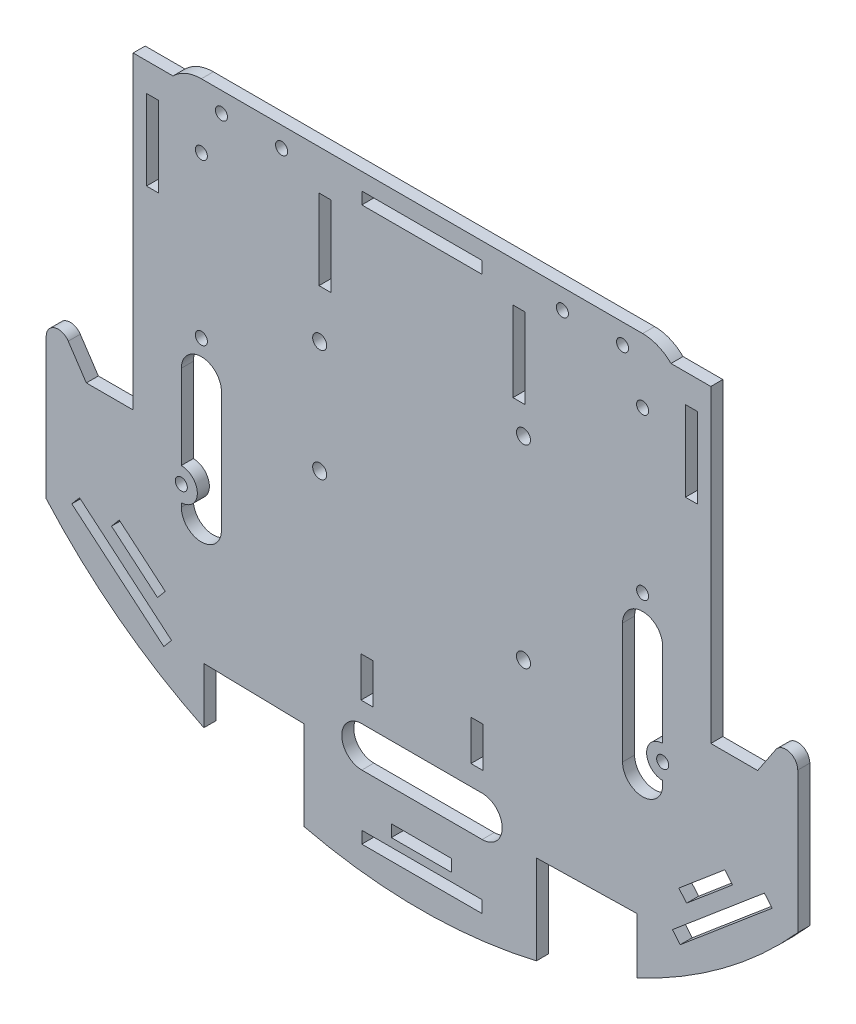
from build123d import *

# Parameters (mm, degrees)
SKETCH1_R           = 1.5
BOSS_EXTRUDE1_DEPTH = 3
SKETCH12_W          = 3
SKETCH12_H          = 20
BOSS_EXTRUDE3_DEPTH = 3
SKETCH13_W          = 3
SKETCH13_H          = 20
CUT_EXTRUDE5_DEPTH  = 3
SKETCH15_W          = 30
SKETCH15_H          = 3
BOSS_EXTRUDE4_DEPTH = 3
CUT_EXTRUDE7_DEPTH  = 3
CUT_EXTRUDE8_DEPTH  = 5
SKETCH18_R          = 1.5
SKETCH18_W          = 30
SKETCH18_H          = 3
CUT_EXTRUDE9_DEPTH  = 3
FILLET4_R           = 3
SKETCH25_R          = 1.5
CUT_EXTRUDE11_DEPTH = 10
CUT_EXTRUDE12_DEPTH = 10
SKETCH27_W          = 15
SKETCH27_H          = 3
CUT_EXTRUDE13_DEPTH = 10
SKETCH34_W          = 3
SKETCH34_H          = 10
CUT_EXTRUDE14_DEPTH = 10
SKETCH35_R          = 1.75
CUT_EXTRUDE15_DEPTH = 10


with BuildPart() as part:
    # Sketch1 → Boss-Extrude1 (new body)
    with BuildSketch(Plane.XY):
        with BuildLine():
            Line((-65, 40), (-65, -45))
            ThreePointArc((-65, -45), (-62.071067812, -52.071067812), (-55, -55))
            Line((-55, -55), (55, -55))
            ThreePointArc((55, -55), (62.071067812, -52.071067812), (65, -45))
            Line((65, -45), (65, 40))
            ThreePointArc((65, 40), (62.071067812, 47.071067812), (55, 50))
            Line((55, 50), (-55, 50))
            ThreePointArc((-55, 50), (-62.071067812, 47.071067812), (-65, 40))
        make_face()
        with Locations((-50, 45)):
            Circle(SKETCH1_R, mode=Mode.SUBTRACT)
        with Locations((50, 45)):
            Circle(SKETCH1_R, mode=Mode.SUBTRACT)
        with Locations((-60, -40)):
            Circle(SKETCH1_R, mode=Mode.SUBTRACT)
        with Locations((60, -40)):
            Circle(SKETCH1_R, mode=Mode.SUBTRACT)
    extrude(amount=BOSS_EXTRUDE1_DEPTH)

    # Sketch12 → Boss-Extrude3 (add)
    with BuildSketch(Plane(origin=(0, 0, 0), x_dir=(-1, 0, 0), z_dir=(0, 0, -1))):
        with BuildLine():
            Line((65, 40), (65, -30))
            Line((65, -30), (72, -30))
            Line((72, -30), (72, 40))
            Line((72, 40), (72, 47.071067812))
            Line((72, 47.071067812), (62.071067812, 47.071067812))
            ThreePointArc((62.071067812, 47.071067812), (64.238795325, 43.826834324), (65, 40))
        make_face()
        with Locations((67.174969976, 30)):
            Rectangle(SKETCH12_W, SKETCH12_H, mode=Mode.SUBTRACT)
        with BuildLine():
            Line((-72, 40), (-72, -30))
            Line((-72, -30), (-65, -30))
            Line((-65, -30), (-65, 40))
            ThreePointArc((-65, 40), (-64.238795325, 43.826834324), (-62.071067812, 47.071067812))
            Line((-62.071067812, 47.071067812), (-72, 47.071067812))
            Line((-72, 47.071067812), (-72, 40))
        make_face()
        with Locations((-67.174969976, 30)):
            Rectangle(SKETCH12_W, SKETCH12_H, mode=Mode.SUBTRACT)
    extrude(amount=-BOSS_EXTRUDE3_DEPTH)

    # Sketch13 → Cut-Extrude5 (cut)
    with BuildSketch(Plane(origin=(0, 0, 0), x_dir=(-1, 0, 0), z_dir=(0, 0, -1))):
        with Locations((24.174969976, 30)):
            Rectangle(SKETCH13_W, SKETCH13_H)
        with Locations((-24.174969976, 30)):
            Rectangle(SKETCH13_W, SKETCH13_H)
    extrude(amount=-CUT_EXTRUDE5_DEPTH, mode=Mode.SUBTRACT)

    # Sketch15 → Boss-Extrude4 (add)
    with BuildSketch(Plane(origin=(0, 0, 0), x_dir=(-1, 0, 0), z_dir=(0, 0, -1))):
        with BuildLine():
            Line((73.674969976, -30), (72, -30))
            Line((72, -30), (65, -30))
            Line((65, -30), (65, -45))
            ThreePointArc((65, -45), (62.071067812, -52.071067812), (55, -55))
            Line((55, -55), (-55, -55))
            ThreePointArc((-55, -55), (-62.071067812, -52.071067812), (-65, -45))
            Line((-65, -45), (-65, -30))
            Line((-65, -30), (-72, -30))
            Line((-72, -30), (-73.674969976, -30))
            Line((-73.674969976, -30), (-83.674969976, -30))
            Line((-83.674969976, -30), (-93.674969976, -15))
            Line((-93.674969976, -15), (-93.674969976, -60))
            ThreePointArc((-93.674969976, -60), (-75.11867005, -76.957696294), (-53.544667826, -89.859717787))
            Line((-53.544667826, -89.859717787), (-53.544667826, -77.921197712))
            Line((-53.544667826, -77.921197712), (-43.544667826, -77.921197712))
            Line((-43.544667826, -77.921197712), (-28.544667826, -78.447755309))
            Line((-28.544667826, -78.447755309), (-28.544667826, -98.657929362))
            ThreePointArc((-28.544667826, -98.657929362), (0.412515012, -102.058251887), (29.36969785, -98.657929362))
            Line((29.36969785, -98.657929362), (29.36969785, -78.447755309))
            Line((29.36969785, -78.447755309), (44.36969785, -77.921197712))
            Line((44.36969785, -77.921197712), (54.36969785, -77.921197712))
            Line((54.36969785, -77.921197712), (54.36969785, -89.791641118))
            ThreePointArc((54.36969785, -89.791641118), (75.506234101, -76.853587855), (93.674969976, -60))
            Line((93.674969976, -60), (93.674969976, -15))
            Line((93.674969976, -15), (83.674969976, -30))
            Line((83.674969976, -30), (73.674969976, -30))
        make_face()
        Polygon((-64.364341028, -77.265224848), (-87.294606331, -57.920899244), (-85.360173771, -55.627872713), (-62.429908467, -74.972198318), align=None, mode=Mode.SUBTRACT)
        with Locations((0, -93.735273214)):
            Rectangle(SKETCH15_W, SKETCH15_H, mode=Mode.SUBTRACT)
        Polygon((-65.960254421, -67.497898332), (-77.422828052, -57.822702946), (-75.487788974, -55.53018822), (-64.025215344, -65.205383606), align=None, mode=Mode.SUBTRACT)
        Polygon((85.360173771, -55.627872713), (87.294606331, -57.920899244), (64.364341028, -77.265224848), (62.429908467, -74.972198318), align=None, mode=Mode.SUBTRACT)
        Polygon((77.394030345, -57.788043022), (65.932380202, -67.464332393), (63.997122328, -65.172002365), (75.458772471, -55.495712994), align=None, mode=Mode.SUBTRACT)
    extrude(amount=-BOSS_EXTRUDE4_DEPTH)

    # Sketch16 → Cut-Extrude7 (cut)
    with BuildSketch(Plane(origin=(0, 0, 0), x_dir=(-1, 0, 0), z_dir=(0, 0, -1))):
        with BuildLine():
            Line((-60, -44), (-60, -45))
            ThreePointArc((-60, -45), (-55, -50), (-50, -45))
            Line((-50, -45), (-50, -15))
            ThreePointArc((-50, -15), (-55, -10), (-60, -15))
            Line((-60, -15), (-60, -36))
            ThreePointArc((-60, -36), (-56, -40), (-60, -44))
        make_face()
        with BuildLine():
            Line((60, -36), (60, -15))
            ThreePointArc((60, -15), (55, -10), (50, -15))
            Line((50, -15), (50, -45))
            ThreePointArc((50, -45), (55, -50), (60, -45))
            Line((60, -45), (60, -44))
            ThreePointArc((60, -44), (56, -40), (60, -36))
        make_face()
    extrude(amount=-CUT_EXTRUDE7_DEPTH, mode=Mode.SUBTRACT)

    # Sketch17 → Cut-Extrude8 (cut)
    with BuildSketch(Plane(origin=(0, 0, 0), x_dir=(-1, 0, 0), z_dir=(0, 0, -1))):
        with BuildLine():
            Line((-15, -69.235273214), (15, -69.235273214))
            ThreePointArc((15, -69.235273214), (20, -74.235273214), (15, -79.235273214))
            Line((15, -79.235273214), (-15, -79.235273214))
            ThreePointArc((-15, -79.235273214), (-20, -74.235273214), (-15, -69.235273214))
        make_face()
    extrude(amount=-CUT_EXTRUDE8_DEPTH, mode=Mode.SUBTRACT)

    # Sketch18 → Cut-Extrude9 (cut)
    with BuildSketch(Plane(origin=(0, 0, 0), x_dir=(-1, 0, 0), z_dir=(0, 0, -1))):
        with Locations((55, 34)):
            Circle(SKETCH18_R)
        with Locations((55, -6)):
            Circle(SKETCH18_R)
        with Locations((-55, 34)):
            Circle(SKETCH18_R)
        with Locations((-55, -6)):
            Circle(SKETCH18_R)
        with Locations((0, 44.264726786)):
            Rectangle(SKETCH18_W, SKETCH18_H)
    extrude(amount=-CUT_EXTRUDE9_DEPTH, mode=Mode.SUBTRACT)

    # Fillet4
    fillet4_edges = [part.edges().sort_by_distance(p)[0] for p in [
        (93.674969976, -15, 1.5),
        (-93.674969976, -15, 1.5),
    ]]
    fillet(fillet4_edges, radius=FILLET4_R)

    # Sketch25 → Cut-Extrude11 (cut)
    with BuildSketch(Plane.XY.offset(3)):
        with Locations((-35, 45)):
            Circle(SKETCH25_R)
        with Locations((35, 45)):
            Circle(SKETCH25_R)
    extrude(amount=-CUT_EXTRUDE11_DEPTH, mode=Mode.SUBTRACT)

    # Sketch26 → Cut-Extrude12 (cut)
    with BuildSketch(Plane.XY.offset(3)):
        Polygon((-54.36969785, -77.921197712), (-54.36969785, -75.921197712), (-29.36969785, -76.450833315), (-29.36969785, -78.447755309), align=None)
        Polygon((28.544667826, -78.447755309), (28.544667826, -76.450833315), (53.544667826, -75.921197712), (53.544667826, -77.921197712), align=None)
    extrude(amount=-CUT_EXTRUDE12_DEPTH, mode=Mode.SUBTRACT)

    # Sketch27 → Cut-Extrude13 (cut)
    with BuildSketch(Plane(origin=(0, 0, 0), x_dir=(-1, 0, 0), z_dir=(0, 0, -1))):
        with Locations((0.14797788, -88.645273214)):
            Rectangle(SKETCH27_W, SKETCH27_H)
    extrude(amount=-CUT_EXTRUDE13_DEPTH, mode=Mode.SUBTRACT)

    # Sketch34 → Cut-Extrude14 (cut)
    with BuildSketch(Plane.XY.offset(3)):
        with Locations((13.7, -59.235273214)):
            Rectangle(SKETCH34_W, SKETCH34_H)
        with Locations((-13.7, -59.235273214)):
            Rectangle(SKETCH34_W, SKETCH34_H)
    extrude(amount=-CUT_EXTRUDE14_DEPTH, mode=Mode.SUBTRACT)

    # Sketch35 → Cut-Extrude15 (cut)
    with BuildSketch(Plane.XY.offset(3)):
        with Locations((25.3, -35.3)):
            Circle(SKETCH35_R)
        with Locations((-25.5, -19.9)):
            Circle(SKETCH35_R)
        with Locations((25.3, 13)):
            Circle(SKETCH35_R)
        with Locations((-25.5, 8)):
            Circle(SKETCH35_R)
    extrude(amount=-CUT_EXTRUDE15_DEPTH, mode=Mode.SUBTRACT)


solid = part.part
